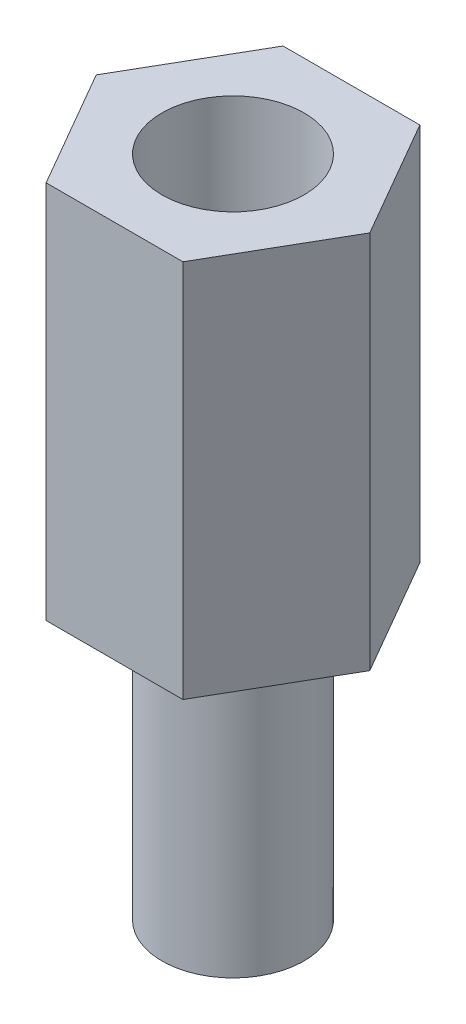
from build123d import *

# Parameters (mm, degrees)
CROQUIS1_R              = 1.5
SALIENTE_EXTRUIR1_DEPTH = 8
CROQUIS2_R              = 1.5
SALIENTE_EXTRUIR2_DEPTH = 6


with BuildPart() as part:
    # Croquis1 → Saliente-Extruir1 (new body)
    with BuildSketch(Plane(origin=(0, 0, 0), x_dir=(1, 0, 0), z_dir=(0, 1, 0))):
        Polygon((1.443375673, -2.5), (2.886751346, 0), (1.443375673, 2.5), (-1.443375673, 2.5), (-2.886751346, 0), (-1.443375673, -2.5), align=None)
        Circle(CROQUIS1_R, mode=Mode.SUBTRACT)
    extrude(amount=SALIENTE_EXTRUIR1_DEPTH)


with BuildPart() as body_2:
    # Croquis2 → Saliente-Extruir2 (new body)
    with BuildSketch(Plane.XZ):
        Circle(CROQUIS2_R)
    extrude(amount=SALIENTE_EXTRUIR2_DEPTH)


solid = Compound([part.part, body_2.part])
